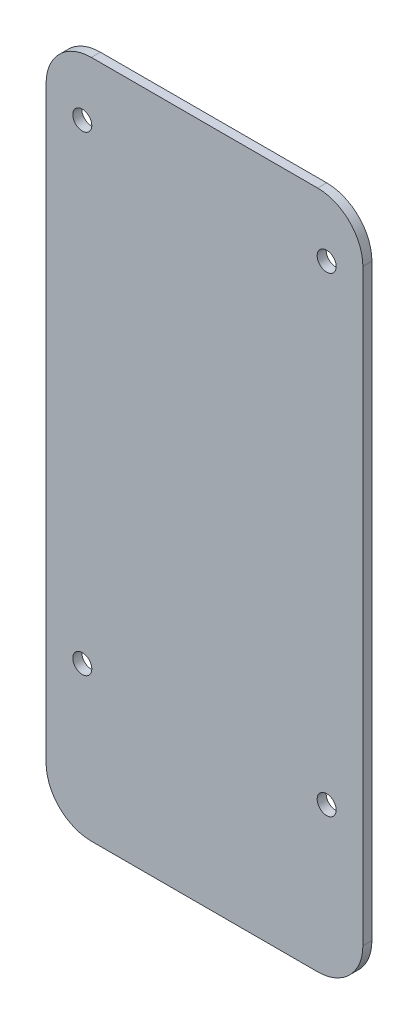
from build123d import *

# Parameters (mm, degrees)
SKETCH_1_W      = 70
SKETCH_1_H      = 150
SKETCH_1_R      = 2.1
EXTRUDE_1_DEPTH = 2
FILLET_1_R      = 10


with BuildPart() as part:
    # 草图1 → 凸台-拉伸1 (new body)
    with BuildSketch(Plane.XY):
        Rectangle(SKETCH_1_W, SKETCH_1_H)
        with Locations((-27, 62)):
            Circle(SKETCH_1_R, mode=Mode.SUBTRACT)
        with Locations((27, 62)):
            Circle(SKETCH_1_R, mode=Mode.SUBTRACT)
        with Locations((27, -42)):
            Circle(SKETCH_1_R, mode=Mode.SUBTRACT)
        with Locations((-27, -42)):
            Circle(SKETCH_1_R, mode=Mode.SUBTRACT)
    extrude(amount=EXTRUDE_1_DEPTH)

    # 圆角1
    fillet_1_edges = [part.edges().sort_by_distance(p)[0] for p in [
        (35, -75, 1),
        (-35, -75, 1),
        (-35, 75, 1),
        (35, 75, 1),
    ]]
    fillet(fillet_1_edges, radius=FILLET_1_R)


solid = part.part
